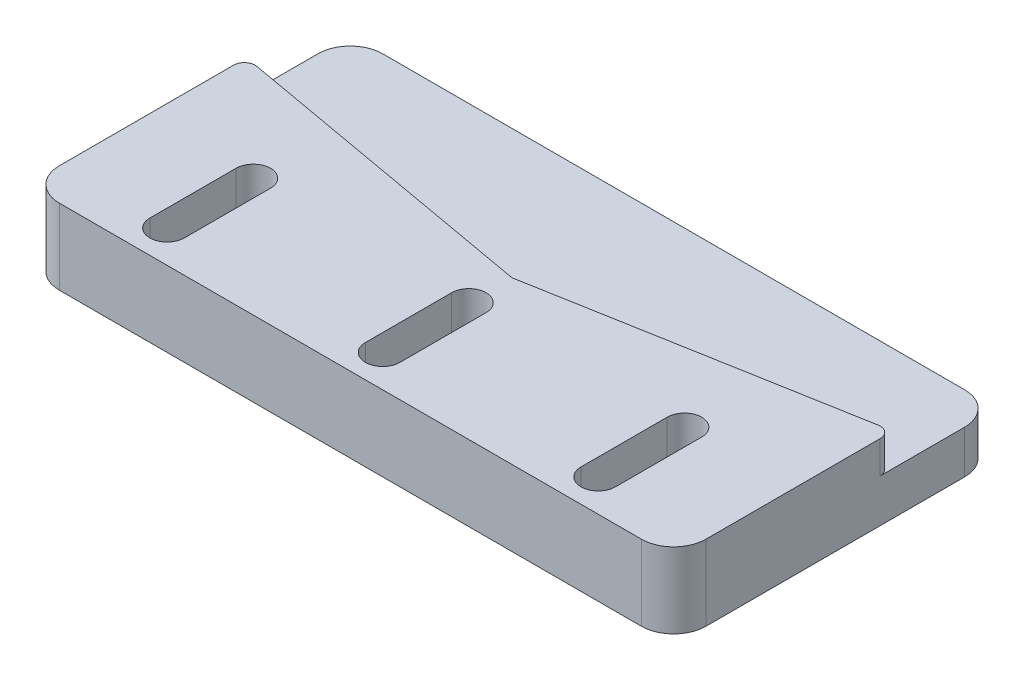
from build123d import *

# Parameters (mm, degrees)
BOSS_EXTRUDE1_DEPTH = 3
SKETCH4_W           = 60
SKETCH4_H           = 30
BOSS_EXTRUDE2_DEPTH = 4
FILLET1_R           = 3
CUT_EXTRUDE1_DEPTH  = 8
BOSS_EXTRUDE3_DEPTH = 3


with BuildPart() as part:
    # Sketch2 → Boss-Extrude1 (new body)
    with BuildSketch(Plane(origin=(0, 0, 0), x_dir=(1, 0, 0), z_dir=(0, 1, 0))):
        with BuildLine():
            Line((-30, -7.5), (30, -7.5))
            Line((30, -7.5), (30, 11.664728706))
            ThreePointArc((30, 11.664728706), (29.572172135, 12.484862261), (28.654761905, 12.60324384))
            ThreePointArc((28.654761905, 12.60324384), (0, 7.5), (-28.654761905, 12.60324384))
            ThreePointArc((-28.654761905, 12.60324384), (-29.572172135, 12.484862261), (-30, 11.664728706))
            Line((-30, 11.664728706), (-30, -7.5))
        make_face()
    extrude(amount=BOSS_EXTRUDE1_DEPTH)

    # Sketch4 → Boss-Extrude2 (add)
    with BuildSketch(Plane.XZ):
        with Locations((0, -7.5)):
            Rectangle(SKETCH4_W, SKETCH4_H)
    extrude(amount=BOSS_EXTRUDE2_DEPTH)

    # Fillet1
    fillet1_edges = [part.edges().sort_by_distance(p)[0] for p in [
        (30, -2, -22.5),
        (30, -0.5, 7.5),
        (-30, -0.5, 7.5),
        (-30, -2, -22.5),
    ]]
    fillet(fillet1_edges, radius=FILLET1_R)

    # Sketch5 → Cut-Extrude1 (cut, through all)
    with BuildSketch(Plane(origin=(0, 3, 0), x_dir=(1, 0, 0), z_dir=(0, 1, 0))):
        with BuildLine():
            Line((1.6, 3.5), (1.6, -4.5))
            ThreePointArc((1.6, -4.5), (0, -6.1), (-1.6, -4.5))
            Line((-1.6, -4.5), (-1.6, 3.5))
            ThreePointArc((-1.6, 3.5), (0, 5.1), (1.6, 3.5))
        make_face()
        with BuildLine():
            Line((21.6, 3.5), (21.6, -4.5))
            ThreePointArc((21.6, -4.5), (20, -6.1), (18.4, -4.5))
            Line((18.4, -4.5), (18.4, 3.5))
            ThreePointArc((18.4, 3.5), (20, 5.1), (21.6, 3.5))
        make_face()
        with BuildLine():
            Line((-21.6, 3.5), (-21.6, -4.5))
            ThreePointArc((-21.6, -4.5), (-20, -6.1), (-18.4, -4.5))
            Line((-18.4, -4.5), (-18.4, 3.5))
            ThreePointArc((-18.4, 3.5), (-20, 5.1), (-21.6, 3.5))
        make_face()
    extrude(amount=-CUT_EXTRUDE1_DEPTH, mode=Mode.SUBTRACT)

    # Sketch6 → Boss-Extrude3 (add)
    with BuildSketch(Plane(origin=(0, 3, 0), x_dir=(1, 0, 0), z_dir=(0, 1, 0))):
        with BuildLine():
            Line((0, 7.5), (-28.824143961, 12.649144601))
            ThreePointArc((-28.824143961, 12.649144601), (-29.64192833, 12.43149335), (-30, 11.664728706))
            Line((-30, 11.664728706), (-30, -4.5))
            ThreePointArc((-30, -4.5), (-29.121320344, -6.621320344), (-27, -7.5))
            Line((-27, -7.5), (27, -7.5))
            ThreePointArc((27, -7.5), (29.121320344, -6.621320344), (30, -4.5))
            Line((30, -4.5), (30, 11.664728706))
            ThreePointArc((30, 11.664728706), (29.64192833, 12.43149335), (28.824143961, 12.649144601))
            Line((28.824143961, 12.649144601), (0, 7.5))
        make_face()
        with BuildLine():
            Line((-18.4, -4.5), (-18.4, 3.5))
            ThreePointArc((-18.4, 3.5), (-20, 5.1), (-21.6, 3.5))
            Line((-21.6, 3.5), (-21.6, -4.5))
            ThreePointArc((-21.6, -4.5), (-20, -6.1), (-18.4, -4.5))
        make_face(mode=Mode.SUBTRACT)
        with BuildLine():
            Line((1.6, -4.5), (1.6, 3.5))
            ThreePointArc((1.6, 3.5), (0, 5.1), (-1.6, 3.5))
            Line((-1.6, 3.5), (-1.6, -4.5))
            ThreePointArc((-1.6, -4.5), (0, -6.1), (1.6, -4.5))
        make_face(mode=Mode.SUBTRACT)
        with BuildLine():
            Line((21.6, -4.5), (21.6, 3.5))
            ThreePointArc((21.6, 3.5), (20, 5.1), (18.4, 3.5))
            Line((18.4, 3.5), (18.4, -4.5))
            ThreePointArc((18.4, -4.5), (20, -6.1), (21.6, -4.5))
        make_face(mode=Mode.SUBTRACT)
    extrude(amount=-BOSS_EXTRUDE3_DEPTH)


solid = part.part
